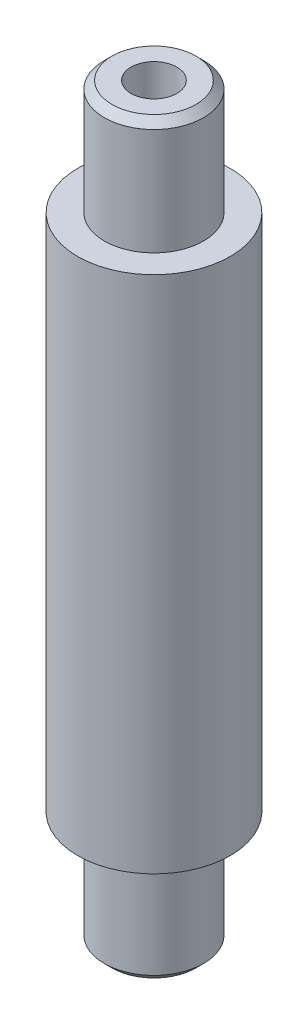
from build123d import *

# Parameters (mm, degrees)
SKETCH_1_R          = 10
EXTRUDE_1_DEPTH     = 34
SKETCH_2_R          = 6.5
EXTRUDE_2_DEPTH     = 49
CHAMFER_1_SIZE      = 1
SKETCH_3_R          = 3
CUT_EXTRUDE_1_DEPTH = 14
CHAMFER_2_SIZE      = 1


with BuildPart() as part:
    # 스케치1 → 보스-돌출1 (new body, symmetric)
    with BuildSketch(Plane(origin=(0, 0, 0), x_dir=(1, 0, 0), z_dir=(0, 1, 0))):
        Circle(SKETCH_1_R)
    extrude(amount=EXTRUDE_1_DEPTH, both=True)

    # 스케치2 → 보스-돌출2 (add, symmetric)
    with BuildSketch(Plane(origin=(0, 0, 0), x_dir=(1, 0, 0), z_dir=(0, 1, 0))):
        Circle(SKETCH_2_R)
    extrude(amount=EXTRUDE_2_DEPTH, both=True)

    # 모따기1
    chamfer_1_edges = [part.edges().sort_by_distance(p)[0] for p in [
        (-6.5, -49, 0),
        (-6.5, 49, 0),
    ]]
    chamfer(chamfer_1_edges, length=CHAMFER_1_SIZE)

    # 스케치3 → 컷-돌출1 (cut)
    with BuildSketch(Plane(origin=(0, 49, 0), x_dir=(1, 0, 0), z_dir=(0, 1, 0))):
        Circle(SKETCH_3_R)
    cut_extrude_1 = extrude(amount=-CUT_EXTRUDE_1_DEPTH, mode=Mode.SUBTRACT)

    # 대칭 복사1: 컷-돌출1 across plane
    add(cut_extrude_1.mirror(Plane.ZX), mode=Mode.SUBTRACT)

    # 모따기2
    chamfer_2_edges = [part.edges().sort_by_distance(p)[0] for p in [
        (-3, 35, 0),
        (-3, -35, 0),
    ]]
    chamfer(chamfer_2_edges, length=CHAMFER_2_SIZE)


solid = part.part
